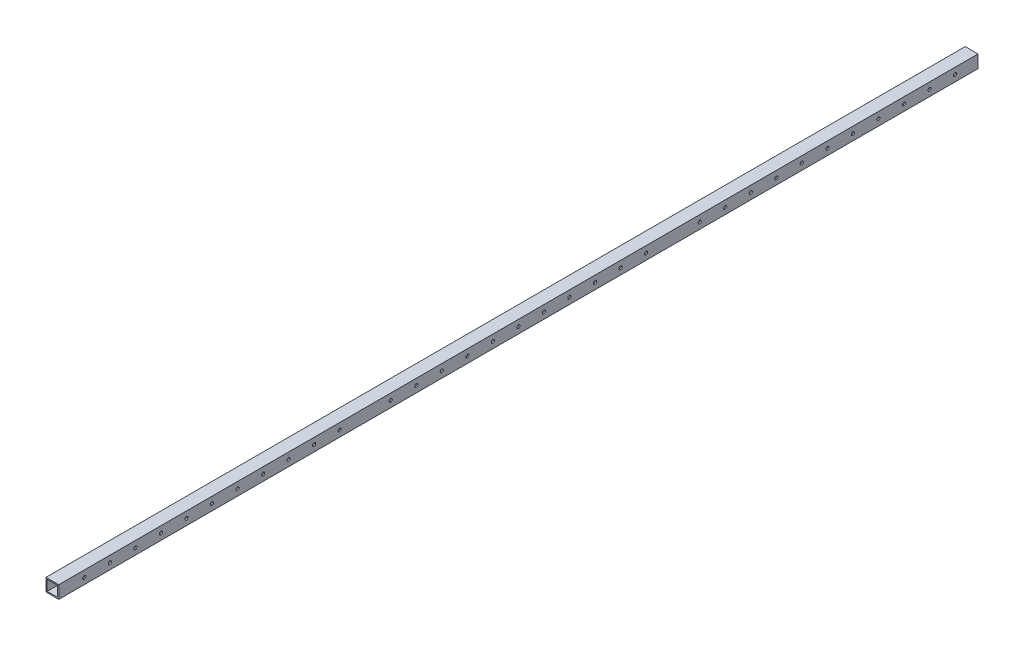
from build123d import *

# Parameters (mm, degrees)
SKETCH1_W           = 50.8
SKETCH1_H           = 50.8
SKETCH1_W_2         = 41.275
SKETCH1_H_2         = 41.275
BOSS_EXTRUDE1_DEPTH = 3657.6
CUT_EXTRUDE1_START  = -51.8
SKETCH2_R           = 6.35
CUT_EXTRUDE1_DEPTH  = 52.8
LPATTERN1_COUNT     = 11
LPATTERN1_PITCH     = 101.6
SKETCH3_R           = 6.35
CUT_EXTRUDE2_DEPTH  = 51.8
LPATTERN2_COUNT     = 11
LPATTERN2_PITCH     = 101.6
SKETCH4_R           = 6.35
CUT_EXTRUDE3_DEPTH  = 51.8
LPATTERN3_COUNT     = 11
LPATTERN3_PITCH     = 101.6


with BuildPart() as part:
    # Sketch1 → Boss-Extrude1 (new body)
    with BuildSketch(Plane.XY):
        with Locations((25.4, 25.4)):
            Rectangle(SKETCH1_W, SKETCH1_H)
        with Locations((25.4, 25.4)):
            Rectangle(SKETCH1_W_2, SKETCH1_H_2, mode=Mode.SUBTRACT)
    extrude(amount=BOSS_EXTRUDE1_DEPTH)

    # Sketch2 → Cut-Extrude1 (cut)
    with BuildSketch(Plane.ZY.offset(CUT_EXTRUDE1_START)):
        with Locations((3556, 25.4)):
            Circle(SKETCH2_R)
    cut_extrude1 = extrude(amount=CUT_EXTRUDE1_DEPTH, mode=Mode.SUBTRACT)

    # LPattern1: Cut-Extrude1 ×11
    with Locations(*[(0, 0, -i * LPATTERN1_PITCH) for i in range(1, LPATTERN1_COUNT)]):
        add(cut_extrude1, mode=Mode.SUBTRACT)

    # Sketch3 → Cut-Extrude2 (cut, through all)
    with BuildSketch(Plane.ZY):
        with Locations((2336.8, 25.4)):
            Circle(SKETCH3_R)
    cut_extrude2 = extrude(amount=-CUT_EXTRUDE2_DEPTH, mode=Mode.SUBTRACT)

    # LPattern2: Cut-Extrude2 ×11
    with Locations(*[(0, 0, -i * LPATTERN2_PITCH) for i in range(1, LPATTERN2_COUNT)]):
        add(cut_extrude2, mode=Mode.SUBTRACT)

    # Sketch4 → Cut-Extrude3 (cut, through all)
    with BuildSketch(Plane.ZY):
        with Locations((1107.44, 25.4)):
            Circle(SKETCH4_R)
    cut_extrude3 = extrude(amount=-CUT_EXTRUDE3_DEPTH, mode=Mode.SUBTRACT)

    # LPattern3: Cut-Extrude3 ×11
    with Locations(*[(0, 0, -i * LPATTERN3_PITCH) for i in range(1, LPATTERN3_COUNT)]):
        add(cut_extrude3, mode=Mode.SUBTRACT)


solid = part.part
